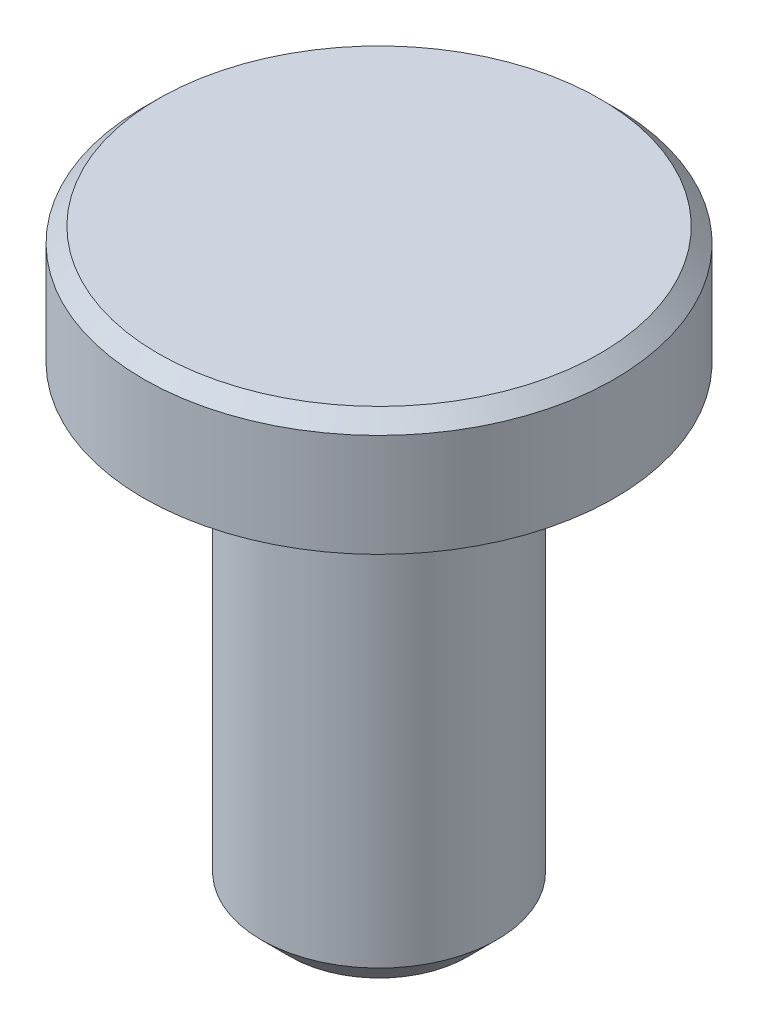
from build123d import *

# Parameters (mm, degrees)
SKETCH1_R           = 4
BOSS_EXTRUDE1_DEPTH = 16
SKETCH2_R           = 8
BOSS_EXTRUDE2_DEPTH = 4
CHAMFER1_SIZE       = 1
CHAMFER2_SIZE       = 0.5
FILLET1_R           = 0.3


with BuildPart() as part:
    # Sketch1 → Boss-Extrude1 (new body)
    with BuildSketch(Plane(origin=(0, 0, 0), x_dir=(1, 0, 0), z_dir=(0, 1, 0))):
        Circle(SKETCH1_R)
    extrude(amount=-BOSS_EXTRUDE1_DEPTH)

    # Sketch2 → Boss-Extrude2 (add)
    with BuildSketch(Plane(origin=(0, 0, 0), x_dir=(1, 0, 0), z_dir=(0, 1, 0))):
        Circle(SKETCH2_R)
    extrude(amount=BOSS_EXTRUDE2_DEPTH)

    # Chamfer1
    chamfer1_edges = [part.edges().sort_by_distance(p)[0] for p in [
        (-4, -16, 0),
    ]]
    chamfer(chamfer1_edges, length=CHAMFER1_SIZE)

    # Chamfer2
    chamfer2_edges = [part.edges().sort_by_distance(p)[0] for p in [
        (-8, 4, 0),
    ]]
    chamfer(chamfer2_edges, length=CHAMFER2_SIZE)

    # Fillet1
    fillet1_edges = [part.edges().sort_by_distance(p)[0] for p in [
        (-4, 0, 0),
    ]]
    fillet(fillet1_edges, radius=FILLET1_R)


solid = part.part
